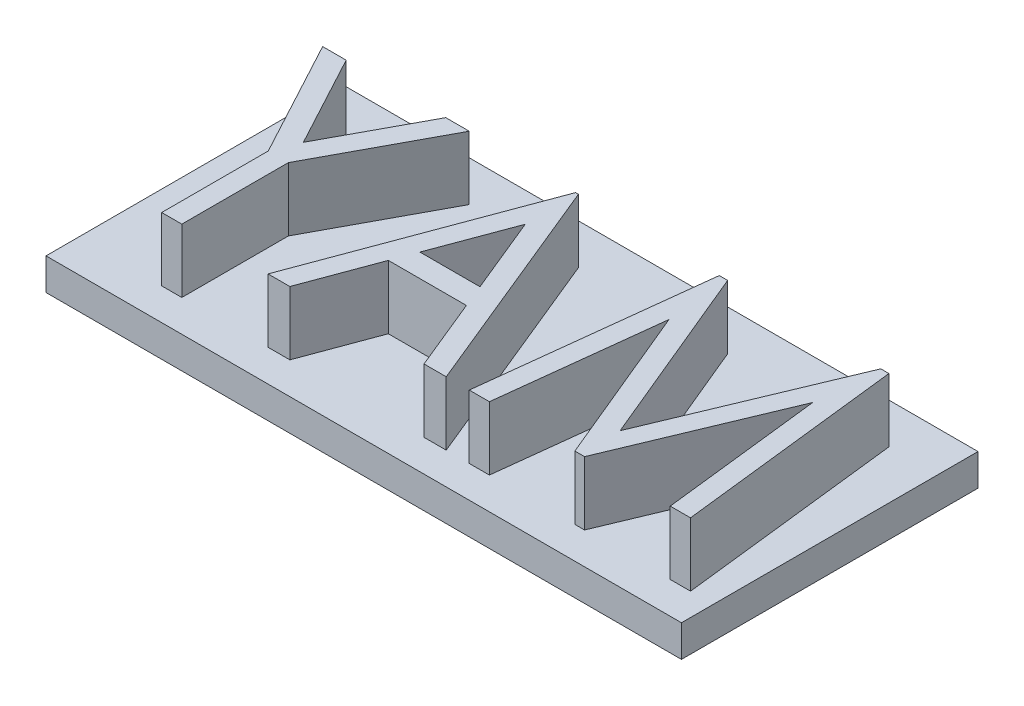
from build123d import *

# Parameters (mm, degrees)
SKETCH1_W           = 15
SKETCH1_H           = 7
BOSS_EXTRUDE1_DEPTH = 0.75
BOSS_EXTRUDE2_DEPTH = 1.5


with BuildPart() as part:
    # Sketch1 → Boss-Extrude1 (new body)
    with BuildSketch(Plane(origin=(0, 0, 0), x_dir=(1, 0, 0), z_dir=(0, 1, 0))):
        Rectangle(SKETCH1_W, SKETCH1_H)
    extrude(amount=BOSS_EXTRUDE1_DEPTH)

    # Sketch2 → Boss-Extrude2 (add)
    with BuildSketch(Plane(origin=(0, 0.75, 0), x_dir=(1, 0, 0), z_dir=(0, 1, 0))):
        Polygon((6.962231563, -2.748114094), (6.353774698, 2.543552573), (6.161909381, 2.543552573), (4.35031917, -1.798327769), (2.547209194, 2.543552573), (2.348983699, 2.543552573), (1.738406776, -2.748114094), (2.214359968, -2.748114094), (2.654272161, 1.051031205), (4.231595879, -2.748114094), (4.460562225, -2.748114094), (6.046366178, 1.051031205), (6.483098283, -2.748114094), align=None)
        Polygon((-1.043110318, 2.543552573), (-3.010524848, -2.748114094), (-2.495350569, -2.748114094), (-1.866753146, -1.052067085), (-0.024422083, -1.052067085), (0.67095719, -2.748114094), (1.195671734, -2.748114094), (-0.975268437, 2.543552573), align=None)
        Polygon((-0.990108849, 1.302258169), (-0.247028253, -0.509332042), (-1.664287535, -0.509332042), align=None, mode=Mode.SUBTRACT)
        Polygon((-3.55325989, 2.543552573), (-4.107655256, 2.543552573), (-5.283227839, 0.35883202), (-6.457740392, 2.543552573), (-7.013195788, 2.543552573), (-5.52067442, -0.232664374), (-5.52067442, -2.748114094), (-5.045781258, -2.748114094), (-5.045781258, -0.232664374), align=None)
    extrude(amount=BOSS_EXTRUDE2_DEPTH)


solid = part.part
